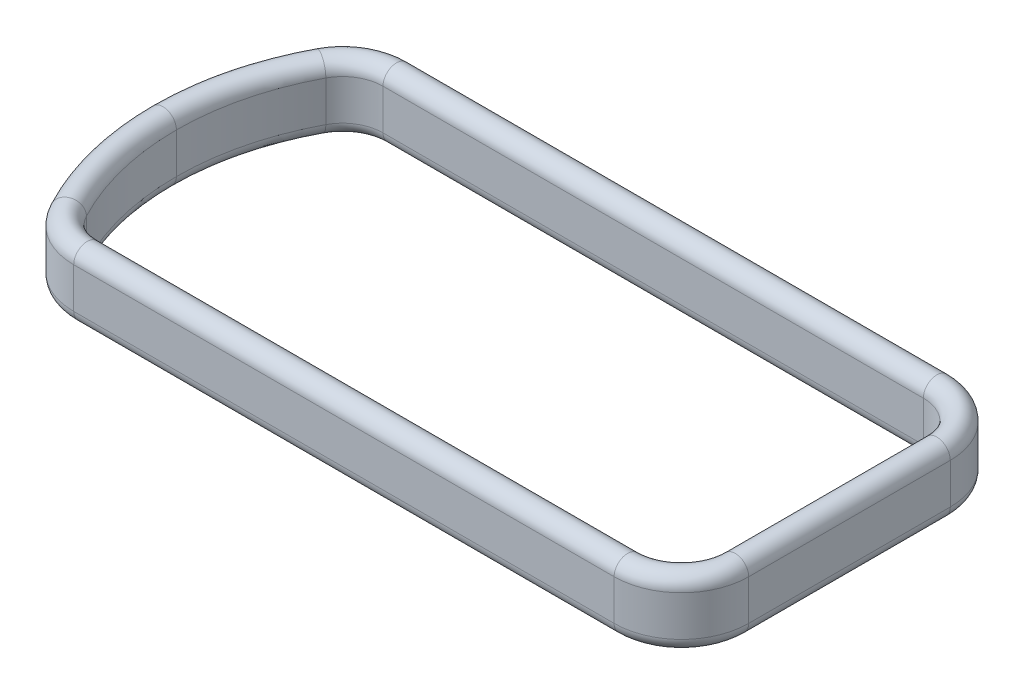
from build123d import *


with BuildPart() as part:
    # Austragung1: sweep along a path in Skizze1
    with BuildLine(Plane(origin=(0, 0, 0), x_dir=(1, 0, 0), z_dir=(0, 1, 0))) as austragung1_path:
        Line((-100.35104183, -57.432811357), (100.35104183, -57.432811357))
        ThreePointArc((100.35104183, -57.432811357), (114.493177454, -51.574946981), (120.35104183, -37.432811357))
        Line((120.35104183, -37.432811357), (120.35104183, 37.432811357))
        ThreePointArc((120.35104183, 37.432811357), (114.493177454, 51.574946981), (100.35104183, 57.432811357))
        Line((100.35104183, 57.432811357), (-100.35104183, 57.432811357))
        ThreePointArc((-100.35104183, 57.432811357), (-110.666950496, 54.567046922), (-118.026562745, 46.791014197))
        ThreePointArc((-118.026562745, 46.791014197), (-129.64895817, 0), (-118.026562745, -46.791014197))
        ThreePointArc((-118.026562745, -46.791014197), (-110.666950496, -54.567046922), (-100.35104183, -57.432811357))
    # Skizze2 → Austragung1 (sweep)
    with BuildSketch(Plane.XY):
        with BuildLine():
            Line((-124.64895817, 0), (-124.64895817, -15))
            ThreePointArc((-124.64895817, -15), (-129.64895817, -20), (-134.64895817, -15))
            Line((-134.64895817, -15), (-134.64895817, 0))
            ThreePointArc((-134.64895817, 0), (-129.64895817, 5), (-124.64895817, 0))
        make_face()
    sweep(path=austragung1_path.line)


solid = part.part
